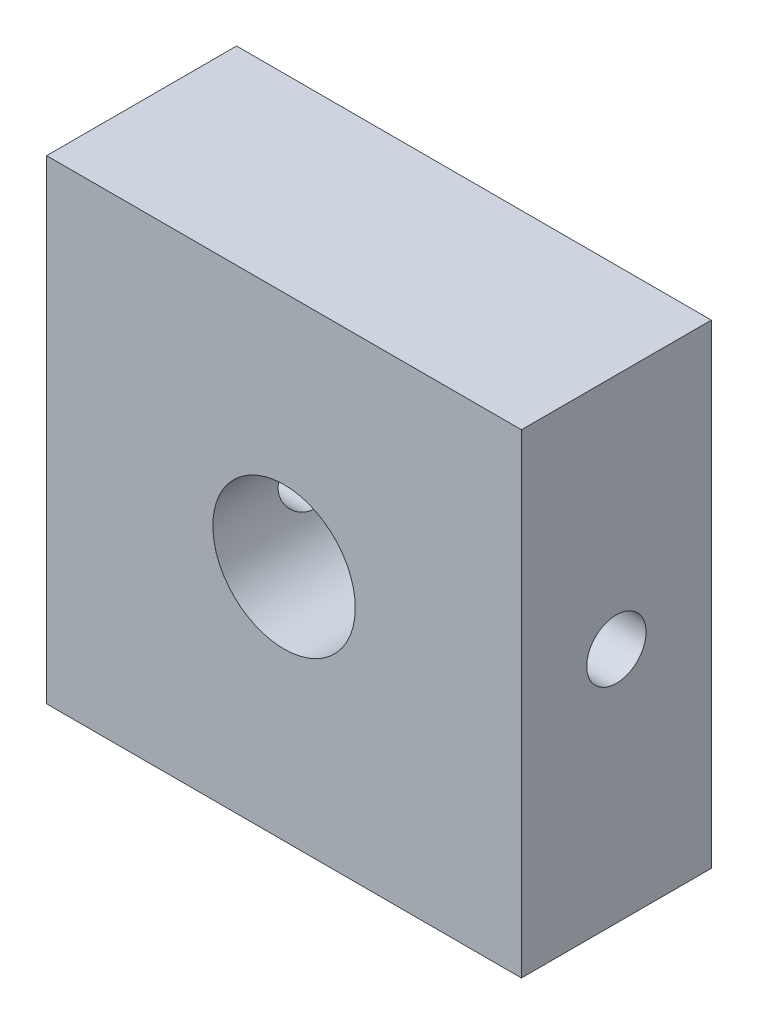
from build123d import *

# Parameters (mm, degrees)
SKETCH1_W           = 20
SKETCH1_H           = 20
BOSS_EXTRUDE1_DEPTH = 8
SKETCH2_R           = 3
CUT_EXTRUDE1_DEPTH  = 9
SKETCH3_R           = 1.25
CUT_EXTRUDE2_DEPTH  = 21


with BuildPart() as part:
    # Sketch1 → Boss-Extrude1 (new body)
    with BuildSketch(Plane.XY):
        with Locations((-162.646542572, -136.36630872)):
            Rectangle(SKETCH1_W, SKETCH1_H)
    extrude(amount=BOSS_EXTRUDE1_DEPTH)

    # Sketch2 → Cut-Extrude1 (cut, through all)
    with BuildSketch(Plane.XY.offset(8)):
        with Locations((-162.646542572, -136.36630872)):
            Circle(SKETCH2_R)
    extrude(amount=-CUT_EXTRUDE1_DEPTH, mode=Mode.SUBTRACT)

    # Sketch3 → Cut-Extrude2 (cut, through all)
    with BuildSketch(Plane(origin=(-152.646542572, 0, 0), x_dir=(0, 0, -1), z_dir=(1, 0, 0))):
        with Locations((-4, -136.36630872)):
            Circle(SKETCH3_R)
    extrude(amount=-CUT_EXTRUDE2_DEPTH, mode=Mode.SUBTRACT)


solid = part.part
